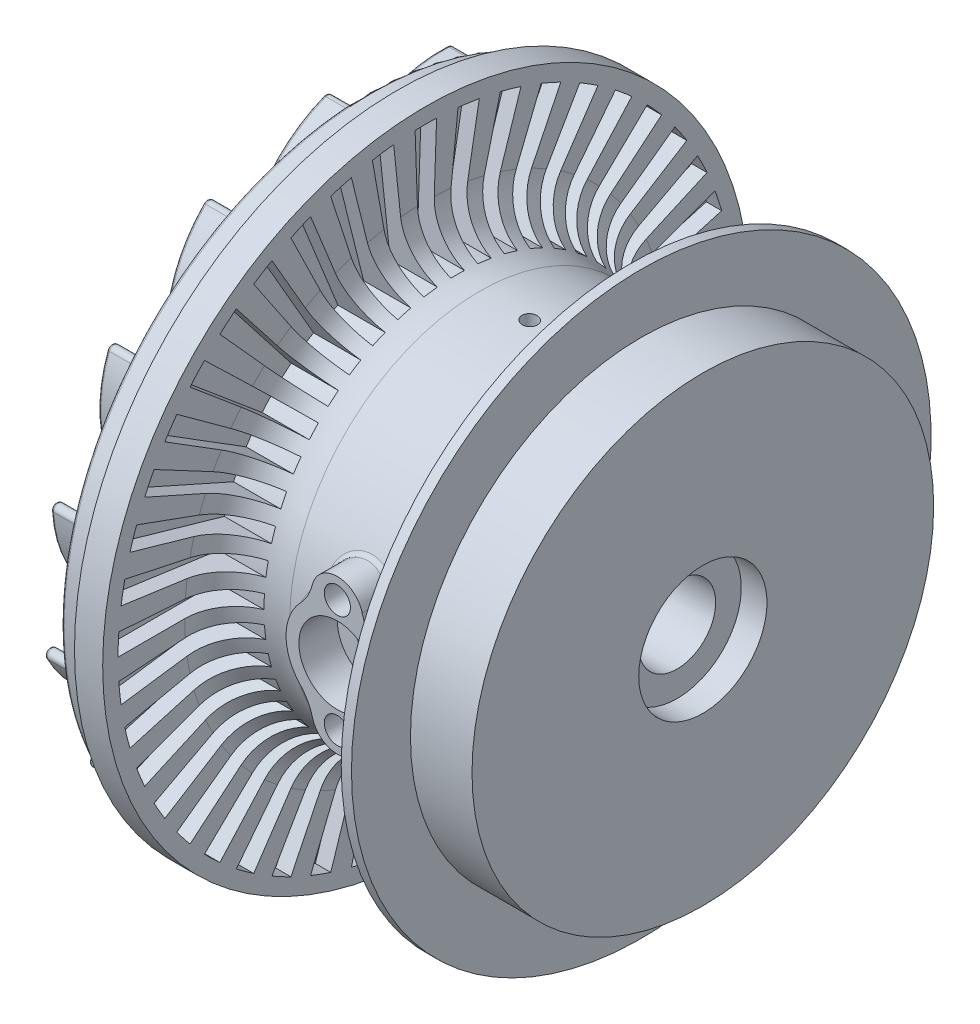
from build123d import *

# Parameters (mm, degrees)
CUT_EXTRUDE1_START             = -3
CUT_EXTRUDE1_DEPTH             = 23
CIRPATTERN1_COUNT              = 45
FILLET1_R                      = 0.5
BOSS_EXTRUDE1_DEPTH            = 5.5
FILLET2_R                      = 0.5
CIRPATTERN2_COUNT              = 15
FILLET2_OF_CIRPATTERN2_R       = 0.5
CUT_SWEEP1_PROFILE_R           = 1.5
CUT_SWEEP2_PROFILE_R           = 1.5
CUT_EXTRUDE2_START             = -13.5
SKETCH19_R                     = 1.5
CUT_EXTRUDE2_DEPTH             = 50.5
CUT_EXTRUDE3_START             = 15.5
SKETCH20_R                     = 1.5
CUT_EXTRUDE3_DEPTH             = 48.5
BOSS_EXTRUDE2_START            = 33.69013
BOSS_EXTRUDE2_DEPTH            = 6.30987
FILLET3_R                      = 1
SKETCH22_R                     = 7.5
SKETCH22_R_2                   = 3.75
CUT_EXTRUDE4_DEPTH             = 7.5
CUT_EXTRUDE5_REACH             = 105
SKETCH22_3_R                   = 3.75
F_5_1_5_1_DIAMETER_HOLE1_D     = 5.1
F_5_1_5_1_DIAMETER_HOLE1_DEPTH = 11.5
F_5_1_5_1_DIAMETER_HOLE1_TIP   = 1.189084528


with BuildPart() as part:
    # Sketch1 → Revolve1 (revolve)
    with BuildSketch(Plane.XY):
        with BuildLine():
            Line((-31.25, 42), (-33.75, 42))
            Line((-33.75, 42), (-33.75, 60))
            Line((-33.75, 60), (-28.25, 60))
            Line((-28.25, 60), (-28.25, 63))
            Line((-28.25, 63), (-22.75, 63))
            Line((-22.75, 63), (-22.75, 47))
            ThreePointArc((-22.75, 47), (-19.651691515, 39.763519209), (-12.276669153, 37.011208386))
            ThreePointArc((-12.276669153, 37.011208386), (-0.394386165, 36.931749147), (11.409998703, 35.571065245))
            ThreePointArc((11.409998703, 35.571065245), (15.474902597, 36.679004941), (17.25, 40.5))
            Line((17.25, 40.5), (17.25, 56.5))
            Line((17.25, 56.5), (19.25, 56.5))
            Line((19.25, 56.5), (19.25, 45))
            Line((19.25, 45), (31.25, 45))
            Line((31.25, 45), (31.25, 12.5))
            Line((31.25, 12.5), (26.25, 12.5))
            Line((26.25, 12.5), (26.25, 7.5))
            Line((26.25, 7.5), (-31.25, 7.5))
            Line((-31.25, 7.5), (-31.25, 42))
        make_face()
    revolve(axis=Axis((-31.25, 0, 0), (1, 0, 0)))

    # Sketch2 → Cut-Extrude1 (cut)
    with BuildSketch(Plane(origin=(-22.75, 0, 0), x_dir=(0, 0, -1), z_dir=(1, 0, 0)).offset(CUT_EXTRUDE1_START)):
        with BuildLine():
            Line((-2.093969802, 59.963449621), (-1.317456001, 37.72700372))
            ThreePointArc((-1.317456001, 37.72700372), (0, 37.75), (1.317456001, 37.72700372))
            Line((1.317456001, 37.72700372), (2.093969802, 59.963449621))
            ThreePointArc((2.093969802, 59.963449621), (0, 60), (-2.093969802, 59.963449621))
        make_face()
    cut_extrude1 = extrude(amount=CUT_EXTRUDE1_DEPTH, mode=Mode.SUBTRACT)

    # CirPattern1: Cut-Extrude1 ×45 about axis
    cirpattern1_axis = Axis((0, 0, 0), (1, 0, 0))
    for i in range(1, CIRPATTERN1_COUNT):
        add(cut_extrude1.rotate(cirpattern1_axis, i * 360 / CIRPATTERN1_COUNT), mode=Mode.SUBTRACT)

    # Fillet1
    fillet1_edges = [part.edges().sort_by_distance(p)[0] for p in [
        (-33.75, -42, 0),
        (-33.75, -60, 0),
    ]]
    fillet(fillet1_edges, radius=FILLET1_R)

    # Sketch4 → Boss-Extrude1 (add)
    with BuildSketch(Plane.ZY.offset(33.75)):
        with BuildLine():
            ThreePointArc((0.776140272, 45.130560289), (-8.760061114, 52.457650898), (-20.573352032, 54.709661412))
            ThreePointArc((-20.573352032, 54.709661412), (-21.52734524, 53.66568011), (-20.483363938, 52.711686902))
            ThreePointArc((-20.483363938, 52.711686902), (-9.578787706, 50.632907966), (-0.776140272, 43.869439711))
            ThreePointArc((-0.776140272, 43.869439711), (0.630560289, 43.723859728), (0.776140272, 45.130560289))
        make_face()
    boss_extrude1 = extrude(amount=BOSS_EXTRUDE1_DEPTH)

    # Fillet2
    fillet2_edges = [part.edges().sort_by_distance(p)[0] for p in [
        (-33.75, 43.723859728, 0.630560289),
        (-33.75, 52.457650898, -8.760061114),
        (-33.75, 53.66568011, -21.52734524),
        (-33.75, 50.632907966, -9.578787706),
        (-39.25, 43.723859728, 0.630560289),
        (-39.25, 52.457650898, -8.760061114),
        (-39.25, 53.66568011, -21.52734524),
        (-39.25, 50.632907966, -9.578787706),
    ]]
    fillet(fillet2_edges, radius=FILLET2_R)

    # CirPattern2: Boss-Extrude1 ×15 about axis
    cirpattern2_axis = Axis((0, 0, 0), (1, 0, 0))
    for i in range(1, CIRPATTERN2_COUNT):
        add(boss_extrude1.rotate(cirpattern2_axis, i * 360 / CIRPATTERN2_COUNT))

    # Fillet2 of CirPattern2
    fillet2_of_cirpattern2_edges = [part.edges().sort_by_distance(p)[0] for p in [
        (-33.75, 39.68726147, 18.360141416),
        (-33.75, 51.485486547, 13.33373479),
        (-33.75, 57.781998433, 2.161590117),
        (-33.75, 50.151507035, 11.843601017),
        (-39.25, 39.68726147, 18.360141416),
        (-39.25, 51.485486547, 13.33373479),
        (-39.25, 57.781998433, 2.161590117),
        (-39.25, 50.151507035, 11.843601017),
        (-33.75, 28.788375156, 32.915087295),
        (-33.75, 41.611013841, 33.122006816),
        (-33.75, 51.907284294, 25.476766906),
        (-33.75, 40.998454927, 31.218123528),
        (-39.25, 28.788375156, 32.915087295),
        (-39.25, 41.611013841, 33.122006816),
        (-39.25, 51.907284294, 25.476766906),
        (-39.25, 40.998454927, 31.218123528),
        (-33.75, 12.911717244, 41.778715557),
        (-33.75, 24.541618818, 47.18318296),
        (-33.75, 37.057329138, 44.386779247),
        (-33.75, 24.756397502, 45.194748873),
        (-39.25, 12.911717244, 41.778715557),
        (-39.25, 24.541618818, 47.18318296),
        (-39.25, 37.057329138, 44.386779247),
        (-39.25, 24.756397502, 45.194748873),
        (-33.75, -5.197493879, 43.418424351),
        (-33.75, 3.228754948, 53.085958124),
        (-33.75, 15.799825118, 55.621914216),
        (-33.75, 4.233734044, 51.356791557),
        (-39.25, -5.197493879, 43.418424351),
        (-39.25, 3.228754948, 53.085958124),
        (-39.25, 15.799825118, 55.621914216),
        (-39.25, 4.233734044, 51.356791557),
        (-33.75, -22.408011093, 37.550693131),
        (-33.75, -18.642389985, 49.809688857),
        (-33.75, -8.189612201, 57.239514907),
        (-33.75, -17.020980492, 48.638778419),
        (-39.25, -22.408011093, 37.550693131),
        (-39.25, -18.642389985, 49.809688857),
        (-39.25, -8.189612201, 57.239514907),
        (-39.25, -17.020980492, 48.638778419),
        (-33.75, -35.743979618, 25.190105932),
        (-33.75, -37.290096329, 37.920871881),
        (-33.75, -30.762991171, 48.959883466),
        (-33.75, -35.33261287, 37.510678622),
        (-39.25, -35.743979618, 25.190105932),
        (-39.25, -37.290096329, 37.920871881),
        (-39.25, -30.762991171, 48.959883466),
        (-39.25, -35.33261287, 37.510678622),
        (-33.75, -42.899489343, 8.473920572),
        (-33.75, -49.490006248, 19.475191656),
        (-33.75, -48.017169494, 32.214643387),
        (-33.75, -47.534915497, 19.896641719),
        (-39.25, -42.899489343, 8.473920572),
        (-39.25, -49.490006248, 19.475191656),
        (-39.25, -48.017169494, 32.214643387),
        (-39.25, -47.534915497, 19.896641719),
        (-33.75, -42.637287632, -9.707482639),
        (-33.75, -53.132644484, -2.337926133),
        (-33.75, -56.968742989, 9.899198806),
        (-33.75, -51.517999393, -1.157705294),
        (-39.25, -42.637287632, -9.707482639),
        (-39.25, -53.132644484, -2.337926133),
        (-39.25, -56.968742989, 9.899198806),
        (-39.25, -51.517999393, -1.157705294),
        (-33.75, -35.002711541, -26.210373911),
        (-33.75, -47.588165793, -23.746795254),
        (-33.75, -56.069903277, -14.12790718),
        (-33.75, -46.593153167, -22.011874543),
        (-39.25, -35.002711541, -26.210373911),
        (-39.25, -47.588165793, -23.746795254),
        (-39.25, -56.069903277, -14.12790718),
        (-39.25, -46.593153167, -22.011874543),
        (-33.75, -21.315848635, -38.18125342),
        (-33.75, -33.815260912, -41.049627743),
        (-33.75, -45.476067909, -35.712169667),
        (-33.75, -33.611927474, -39.059990713),
        (-39.25, -21.315848635, -38.18125342),
        (-39.25, -33.815260912, -41.049627743),
        (-39.25, -45.476067909, -35.712169667),
        (-39.25, -33.611927474, -39.059990713),
        (-33.75, -3.943281852, -43.550247347),
        (-33.75, -14.195390218, -51.254606671),
        (-33.75, -27.019007263, -51.121473583),
        (-33.75, -14.818894165, -49.354279639),
        (-39.25, -3.943281852, -43.550247347),
        (-39.25, -14.195390218, -51.254606671),
        (-39.25, -27.019007263, -51.121473583),
        (-39.25, -14.818894165, -49.354279639),
        (-33.75, 14.111114187, -41.389007866),
        (-33.75, 7.878992407, -52.597198472),
        (-33.75, -3.890114801, -57.691410293),
        (-33.75, 6.53646057, -51.114765246),
        (-39.25, 14.111114187, -41.389007866),
        (-39.25, 7.878992407, -52.597198472),
        (-39.25, -3.890114801, -57.691410293),
        (-39.25, 6.53646057, -51.114765246),
        (-33.75, 29.725570388, -32.071232918),
        (-33.75, 28.591025665, -44.845256826),
        (-33.75, 19.911413851, -54.285978053),
        (-33.75, 26.761601891, -44.037043579),
        (-39.25, 29.725570388, -32.071232918),
        (-39.25, 28.591025665, -44.845256826),
        (-39.25, 19.911413851, -54.285978053),
        (-39.25, 26.761601891, -44.037043579),
        (-33.75, 40.20020542, -17.20805044),
        (-33.75, 44.359410845, -29.339162869),
        (-33.75, 40.270078159, -41.494007036),
        (-33.75, 42.359419123, -29.344917014),
        (-39.25, 40.20020542, -17.20805044),
        (-39.25, 44.359410845, -29.339162869),
        (-39.25, 40.270078159, -41.494007036),
        (-39.25, 42.359419123, -29.344917014),
    ]]
    fillet(fillet2_of_cirpattern2_edges, radius=FILLET2_OF_CIRPATTERN2_R)

    # Cut-Sweep1: sweep along a path in Sketch5
    with BuildLine(Plane.XY) as cut_sweep1_path:
        Line((12.5, 0), (12.5, 15.5))
        Line((12.5, 15.5), (-12.5, 15.5))
        Line((-12.5, 15.5), (-12.5, 8.5))
    # Cut-Sweep1 profile (on start of the path) → Cut-Sweep1 (sweep, cut)
    with BuildSketch(Plane(origin=(12.5, 0, 0), x_dir=(0, 0, 1), z_dir=(0, 1, 0))):
        Circle(CUT_SWEEP1_PROFILE_R)
    sweep(path=cut_sweep1_path.line, transition=Transition.RIGHT, mode=Mode.SUBTRACT)

    # Cut-Sweep2: sweep along a path in Sketch12
    with BuildLine(Plane.XY) as cut_sweep2_path:
        Line((15.25, 0), (15.25, -13.5))
        Line((15.25, -13.5), (-15.25, -13.5))
        Line((-15.25, -13.5), (-15.25, 0))
    # Cut-Sweep2 profile (on start of the path) → Cut-Sweep2 (sweep, cut)
    with BuildSketch(Plane(origin=(15.25, 0, 0), x_dir=(0, 0, -1), z_dir=(0, -1, 0))):
        Circle(CUT_SWEEP2_PROFILE_R)
    sweep(path=cut_sweep2_path.line, transition=Transition.RIGHT, mode=Mode.SUBTRACT)

    # Sketch19 → Cut-Extrude2 (cut, through all)
    with BuildSketch(Plane(origin=(0, 0, 0), x_dir=(1, 0, 0), z_dir=(0, 1, 0)).offset(CUT_EXTRUDE2_START)):
        Circle(SKETCH19_R)
    extrude(amount=-CUT_EXTRUDE2_DEPTH, mode=Mode.SUBTRACT)

    # Sketch20 → Cut-Extrude3 (cut, through all)
    with BuildSketch(Plane(origin=(0, 0, 0), x_dir=(1, 0, 0), z_dir=(0, 1, 0)).offset(CUT_EXTRUDE3_START)):
        with Locations((-2.5, 0)):
            Circle(SKETCH20_R)
    extrude(amount=CUT_EXTRUDE3_DEPTH, mode=Mode.SUBTRACT)

    # Sketch21 → Boss-Extrude2 (add)
    with BuildSketch(Plane.XY.offset(BOSS_EXTRUDE2_START)):
        with BuildLine():
            ThreePointArc((-7.261843774, 6.875), (-10, 0), (-7.261843774, -6.875))
            ThreePointArc((-7.261843774, -6.875), (-5.773687548, -8.908770817), (-4.841229183, -11.25))
            ThreePointArc((-4.841229183, -11.25), (0, -15), (4.841229183, -11.25))
            ThreePointArc((4.841229183, -11.25), (5.773687548, -8.908770817), (7.261843774, -6.875))
            ThreePointArc((7.261843774, -6.875), (10, 0), (7.261843774, 6.875))
            ThreePointArc((7.261843774, 6.875), (5.773687548, 8.908770817), (4.841229183, 11.25))
            ThreePointArc((4.841229183, 11.25), (0, 15), (-4.841229183, 11.25))
            ThreePointArc((-4.841229183, 11.25), (-5.773687548, 8.908770817), (-7.261843774, 6.875))
        make_face()
    extrude(amount=BOSS_EXTRUDE2_DEPTH)

    # Fillet3
    fillet3_edges = [part.edges().sort_by_distance(p)[0] for p in [
        (-0.054282358, -14.999705337, 33.725316311),
        (5.76207413, -8.929820549, 35.270598626),
        (10, 0, 35.801947833),
        (5.762074118, 8.929820543, 35.27059863),
        (-0.054282358, 14.999705332, 33.725316311),
        (-5.762080921, -8.929808194, 36.036817055),
        (-5.762080921, 8.929808194, 36.036817055),
        (-10.000000009, 1e-09, 37.095472229),
    ]]
    fillet(fillet3_edges, radius=FILLET3_R)

    # Sketch22 → Cut-Extrude4 (cut)
    with BuildSketch(Plane.XY.offset(40)):
        Circle(SKETCH22_R)
        Circle(SKETCH22_R_2, mode=Mode.SUBTRACT)
    extrude(amount=-CUT_EXTRUDE4_DEPTH, mode=Mode.SUBTRACT)

    # Sketch22_3 → Cut-Extrude5 (cut, up to next)
    with BuildSketch(Plane.XY.offset(40), mode=Mode.PRIVATE) as cut_extrude5_sk1:
        Circle(SKETCH22_3_R)
    cut_extrude5_tool1 = extrude(cut_extrude5_sk1.sketch, amount=-CUT_EXTRUDE5_REACH, mode=Mode.PRIVATE) & part.part
    add(cut_extrude5_tool1.solids().sort_by_distance((0, 0, 40))[0], mode=Mode.SUBTRACT)

    # 5.1 _5.1_ Diameter Hole1
    with Locations(Plane.XY.offset(40)):
        with Locations((0, 11), (0, -11)):
            Hole(F_5_1_5_1_DIAMETER_HOLE1_D / 2, depth=F_5_1_5_1_DIAMETER_HOLE1_DEPTH)
            with Locations((0, 0, -(F_5_1_5_1_DIAMETER_HOLE1_DEPTH + F_5_1_5_1_DIAMETER_HOLE1_TIP / 2))):  # 130° drill point
                Cone(0, F_5_1_5_1_DIAMETER_HOLE1_D / 2, F_5_1_5_1_DIAMETER_HOLE1_TIP, mode=Mode.SUBTRACT)


solid = part.part
